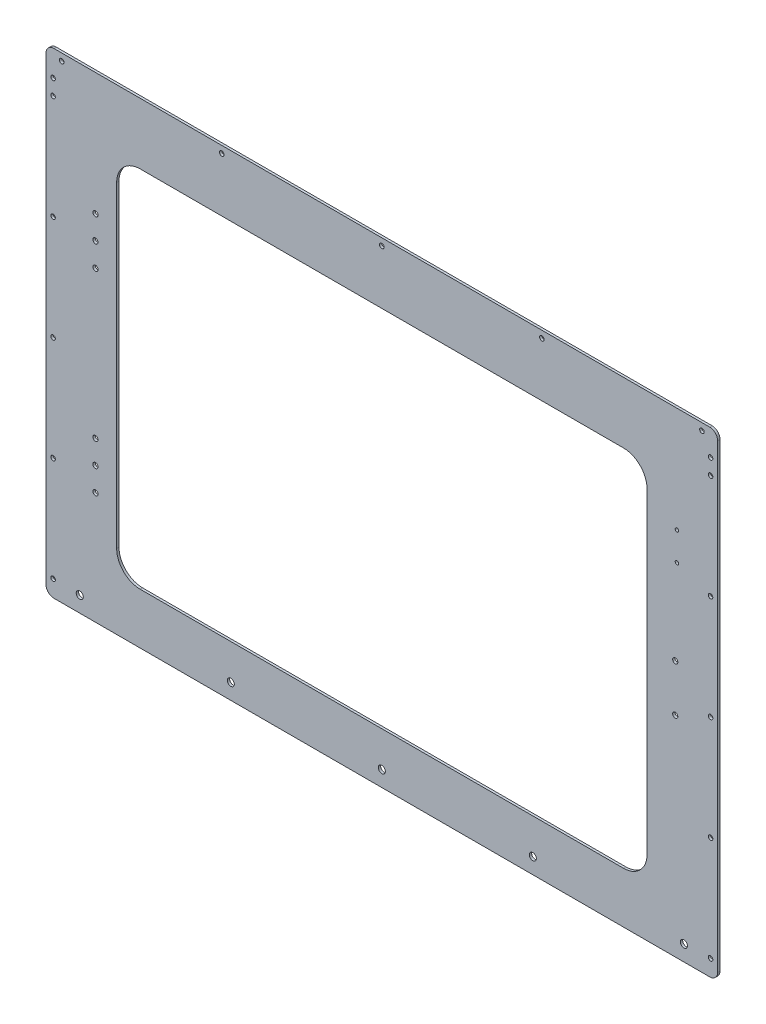
from build123d import *

# Parameters (mm, degrees)
SKETCH1_W            = 856
SKETCH1_H            = 543.9
MAINFRONT_DEPTH      = 3
SKETCH2_W            = 676
SKETCH2_H            = 463.9
DOORCUT_DEPTH        = 4
DOORROUNDINTERNAL_R  = 30
SKETCH3_W            = 856
SKETCH3_H            = 40
BOTTOMMOUNT_DEPTH    = 3
M8_CLEARANCE_HOLE1_D = 9
LPATTERN1_COUNT      = 5
LPATTERN1_PITCH      = 192.5
M5_CLEARANCE_HOLE1_D = 5.8
LPATTERN2_COUNT      = 5
LPATTERN2_PITCH      = 133.225
MIRROR1_COPY_1_D     = 5.8
MIRROR1_COPY_2_D     = 5.8
MIRROR1_COPY_3_D     = 5.8
MIRROR1_COPY_4_D     = 5.8
M5_CLEARANCE_HOLE2_D = 5.8
LPATTERN3_COUNT      = 2
LPATTERN3_PITCH      = 838
M6_CLEARANCE_HOLE1_D = 6.6
FILLET1_R            = 10
M4_CLEARANCE_HOLE1_D = 4.5
M6_CLEARANCE_HOLE2_D = 6.6
SKETCH17_W           = 856
SKETCH17_H           = 23
BOSS_EXTRUDE1_DEPTH  = 3
M5_CLEARANCE_HOLE3_D = 5.8
LPATTERN4_COUNT      = 5
LPATTERN4_PITCH      = 204
FILLET2_R            = 10


with BuildPart() as part:
    # Sketch1 → MainFront (new body)
    with BuildSketch(Plane.XY):
        with Locations((428, 271.95)):
            Rectangle(SKETCH1_W, SKETCH1_H)
    extrude(amount=MAINFRONT_DEPTH)

    # Sketch2 → DoorCut (cut, through all)
    with BuildSketch(Plane.XY.offset(3)):
        with Locations((428, 256.95)):
            Rectangle(SKETCH2_W, SKETCH2_H)
    extrude(amount=-DOORCUT_DEPTH, mode=Mode.SUBTRACT)

    # DoorRoundInternal
    doorroundinternal_edges = [part.edges().sort_by_distance(p)[0] for p in [
        (766, 488.9, 1.5),
        (766, 25, 1.5),
        (90, 25, 1.5),
        (90, 488.9, 1.5),
    ]]
    fillet(doorroundinternal_edges, radius=DOORROUNDINTERNAL_R)

    # Sketch3 → BottomMount (add)
    with BuildSketch(Plane.XY.offset(3)):
        with Locations((428, -20)):
            Rectangle(SKETCH3_W, SKETCH3_H)
    extrude(amount=-BOTTOMMOUNT_DEPTH)

    # M8 Clearance Hole1 (through all)
    with Locations(Plane.XY.offset(3)):
        with Locations((43, -20)):
            m8_clearance_hole1 = Hole(M8_CLEARANCE_HOLE1_D / 2)

    # LPattern1: M8 Clearance Hole1 ×5
    with Locations(*[(i * LPATTERN1_PITCH, 0, 0) for i in range(1, LPATTERN1_COUNT)]):
        add(m8_clearance_hole1, mode=Mode.SUBTRACT)

    # M5 Clearance Hole1 (through all)
    with Locations(Plane.XY.offset(3)):
        with Locations((9, -19)):
            m5_clearance_hole1 = Hole(M5_CLEARANCE_HOLE1_D / 2)

    # LPattern2: M5 Clearance Hole1 ×5
    with Locations(*[(0, i * LPATTERN2_PITCH, 0) for i in range(1, LPATTERN2_COUNT)]):
        add(m5_clearance_hole1, mode=Mode.SUBTRACT)

    # Mirror1: M5 Clearance Hole1 across plane
    add(m5_clearance_hole1.mirror(Plane(origin=(428, 0, 0), x_dir=(0, 0, 1), z_dir=(1, 0, 0))), mode=Mode.SUBTRACT)

    # Mirror1 copy 1 (through all)
    with Locations(Plane(origin=(856, 133.225, 3), x_dir=(-1, 0, 0), z_dir=(0, 0, 1))):
        with Locations((9, 19)):
            Hole(MIRROR1_COPY_1_D / 2)

    # Mirror1 copy 2 (through all)
    with Locations(Plane(origin=(856, 266.45, 3), x_dir=(-1, 0, 0), z_dir=(0, 0, 1))):
        with Locations((9, 19)):
            Hole(MIRROR1_COPY_2_D / 2)

    # Mirror1 copy 3 (through all)
    with Locations(Plane(origin=(856, 399.675, 3), x_dir=(-1, 0, 0), z_dir=(0, 0, 1))):
        with Locations((9, 19)):
            Hole(MIRROR1_COPY_3_D / 2)

    # Mirror1 copy 4 (through all)
    with Locations(Plane(origin=(856, 532.9, 3), x_dir=(-1, 0, 0), z_dir=(0, 0, 1))):
        with Locations((9, 19)):
            Hole(MIRROR1_COPY_4_D / 2)

    # M5 Clearance Hole2 (through all)
    with Locations(Plane.XY.offset(3)):
        with Locations((9, 533.9)):
            m5_clearance_hole2 = Hole(M5_CLEARANCE_HOLE2_D / 2)

    # LPattern3: M5 Clearance Hole2 ×2
    with Locations(*[(i * LPATTERN3_PITCH, 0, 0) for i in range(1, LPATTERN3_COUNT)]):
        add(m5_clearance_hole2, mode=Mode.SUBTRACT)

    # M6 Clearance Hole1 (through all)
    with Locations(Plane.XY.offset(3)):
        with Locations((802, 286.95), (802, 226.95)):
            Hole(M6_CLEARANCE_HOLE1_D / 2)

    # Fillet1
    fillet1_edges = [part.edges().sort_by_distance(p)[0] for p in [
        (0, -40, 1.5),
        (856, -40, 1.5),
    ]]
    fillet(fillet1_edges, radius=FILLET1_R)

    # M4 Clearance Hole1 (through all)
    with Locations(Plane.XY.offset(3)):
        with Locations((804.180642757, 432.408967428), (804.180642757, 396.408967428)):
            Hole(M4_CLEARANCE_HOLE1_D / 2)

    # M6 Clearance Hole2 (through all)
    with Locations(Plane.XY.offset(3)):
        with Locations((63, 410.9), (63, 380.9), (63, 350.9)):
            m6_clearance_hole2 = Hole(M6_CLEARANCE_HOLE2_D / 2)

    # Mirror2: M6 Clearance Hole2 across plane
    add(m6_clearance_hole2.mirror(Plane.ZX.offset(256.95)), mode=Mode.SUBTRACT)

    # Sketch17 → Boss-Extrude1 (add)
    with BuildSketch(Plane(origin=(0, 0, 0), x_dir=(-1, 0, 0), z_dir=(0, 0, -1))):
        with Locations((-428, 555.4)):
            Rectangle(SKETCH17_W, SKETCH17_H)
    extrude(amount=-BOSS_EXTRUDE1_DEPTH)

    # M5 Clearance Hole3 (through all)
    with Locations(Plane.XY.offset(3)):
        with Locations((20, 557.9)):
            m5_clearance_hole3 = Hole(M5_CLEARANCE_HOLE3_D / 2)

    # LPattern4: M5 Clearance Hole3 ×5
    with Locations(*[(i * LPATTERN4_PITCH, 0, 0) for i in range(1, LPATTERN4_COUNT)]):
        add(m5_clearance_hole3, mode=Mode.SUBTRACT)

    # Fillet2
    fillet2_edges = [part.edges().sort_by_distance(p)[0] for p in [
        (856, 566.9, 1.5),
        (0, 566.9, 1.5),
    ]]
    fillet(fillet2_edges, radius=FILLET2_R)


solid = part.part
